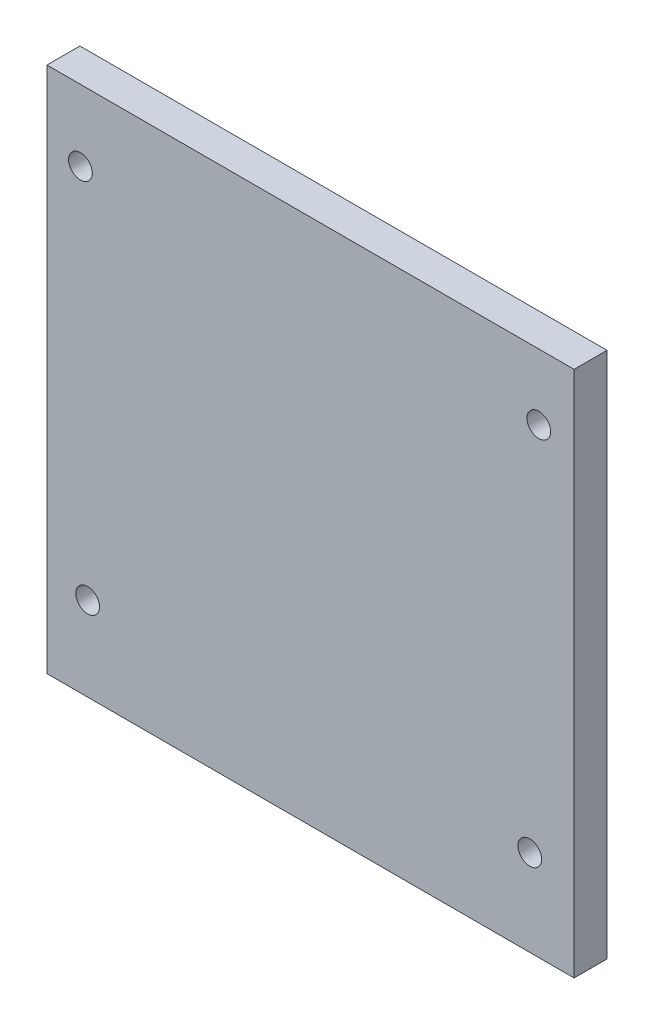
from build123d import *

# Parameters (mm, degrees)
SKETCH1_W           = 101.6
SKETCH1_H           = 101.6
BOSS_EXTRUDE1_DEPTH = 6.35
SKETCH2_R           = 2.286
CUT_EXTRUDE1_DEPTH  = 7.35


with BuildPart() as part:
    # Sketch1 → Boss-Extrude1 (new body)
    with BuildSketch(Plane.XY):
        Rectangle(SKETCH1_W, SKETCH1_H)
    extrude(amount=BOSS_EXTRUDE1_DEPTH)

    # Sketch2 → Cut-Extrude1 (cut, through all)
    with BuildSketch(Plane(origin=(0, 0, 0), x_dir=(-1, 0, 0), z_dir=(0, 0, -1))):
        with Locations((-42.259312367, -34.12311472)):
            Circle(SKETCH2_R)
        with Locations((42.95939041, -34.610988475)):
            Circle(SKETCH2_R)
        with Locations((44.353227794, 37.105683547)):
            Circle(SKETCH2_R)
        with Locations((-44.009030347, 38.128511897)):
            Circle(SKETCH2_R)
    extrude(amount=-CUT_EXTRUDE1_DEPTH, mode=Mode.SUBTRACT)


solid = part.part
